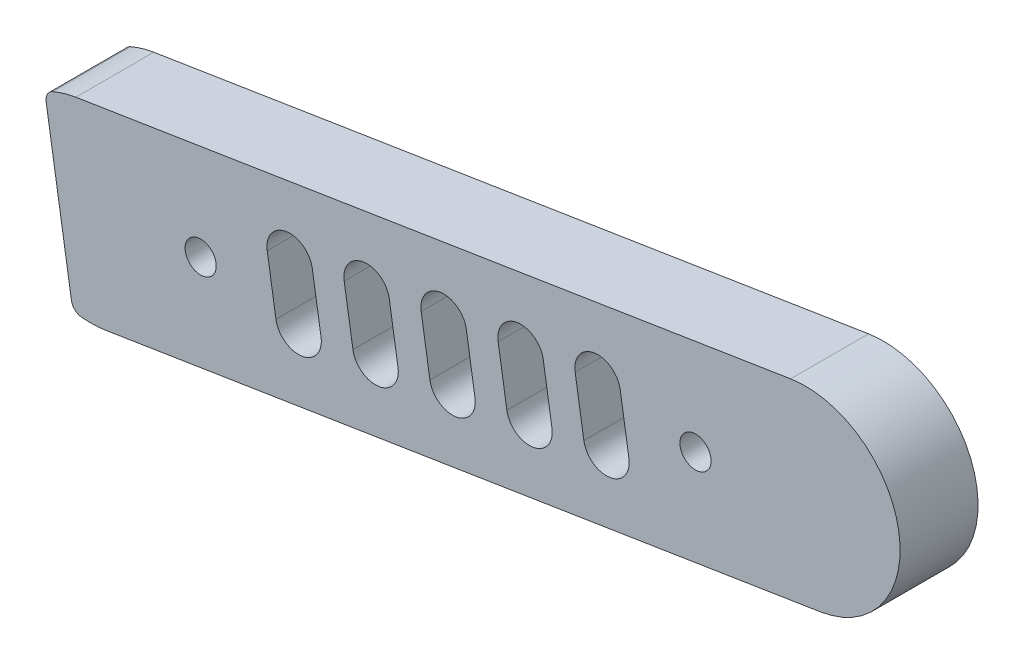
from build123d import *

# Parameters (mm, degrees)
SKETCH_1_R      = 1.4
EXTRUDE_1_DEPTH = 7


with BuildPart() as part:
    # 草图1 → 凸台-拉伸1 (new body)
    with BuildSketch(Plane.XY):
        with BuildLine():
            Line((-42.056135012, 57.617545139), (22.139601015, 67.811046791))
            ThreePointArc((22.139601015, 67.811046791), (31.867424404, 60.749216142), (24.805593755, 51.021392753))
            Line((24.805593755, 51.021392753), (-39.390142272, 40.827891101))
            ThreePointArc((-39.390142272, 40.827891101), (-40.473181997, 40.726394111), (-41.560315394, 40.764045938))
            ThreePointArc((-41.560315394, 40.764045938), (-42.147831339, 41.031589211), (-42.44945072, 41.60236074))
            Line((-42.44945072, 41.60236074), (-44.725061471, 55.933501507))
            ThreePointArc((-44.725061471, 55.933501507), (-44.615083087, 56.569629752), (-44.139340913, 57.006005475))
            ThreePointArc((-44.139340913, 57.006005475), (-43.117343546, 57.378561601), (-42.056135012, 57.617545139))
        make_face()
        with Locations((-30.846871561, 50.790949144)):
            Circle(SKETCH_1_R, mode=Mode.SUBTRACT)
        with Locations((13.596330304, 57.847988749)):
            Circle(SKETCH_1_R, mode=Mode.SUBTRACT)
        with BuildLine():
            Line((6.834080281, 59.305546509), (7.618195793, 54.367412968))
            ThreePointArc((7.618195793, 54.367412968), (5.915048401, 52.021290857), (3.568926289, 53.724438249))
            Line((3.568926289, 53.724438249), (2.784810778, 58.662571789))
            ThreePointArc((2.784810778, 58.662571789), (4.48795817, 61.008693901), (6.834080281, 59.305546509))
        make_face(mode=Mode.SUBTRACT)
        with BuildLine():
            Line((-0.079306676, 58.207784793), (0.704808836, 53.269651252))
            ThreePointArc((0.704808836, 53.269651252), (-0.998338556, 50.923529141), (-3.344460667, 52.626676532))
            Line((-3.344460667, 52.626676532), (-4.128576179, 57.564810073))
            ThreePointArc((-4.128576179, 57.564810073), (-2.425428787, 59.910932184), (-0.079306676, 58.207784793))
        make_face(mode=Mode.SUBTRACT)
        with BuildLine():
            Line((-6.992693633, 57.110023076), (-6.208578121, 52.171889536))
            ThreePointArc((-6.208578121, 52.171889536), (-7.911725513, 49.825767424), (-10.257847624, 51.528914816))
            Line((-10.257847624, 51.528914816), (-11.041963136, 56.467048357))
            ThreePointArc((-11.041963136, 56.467048357), (-9.338815744, 58.813170468), (-6.992693633, 57.110023076))
        make_face(mode=Mode.SUBTRACT)
        with BuildLine():
            Line((-13.906080589, 56.01226136), (-13.121965078, 51.074127819))
            ThreePointArc((-13.121965078, 51.074127819), (-14.82511247, 48.728005708), (-17.171234581, 50.4311531))
            Line((-17.171234581, 50.4311531), (-17.955350093, 55.36928664))
            ThreePointArc((-17.955350093, 55.36928664), (-16.252202701, 57.715408752), (-13.906080589, 56.01226136))
        make_face(mode=Mode.SUBTRACT)
        with BuildLine():
            Line((-20.819467546, 54.914499643), (-20.035352035, 49.976366103))
            ThreePointArc((-20.035352035, 49.976366103), (-21.738499426, 47.630243992), (-24.084621538, 49.333391383))
            Line((-24.084621538, 49.333391383), (-24.868737049, 54.271524924))
            ThreePointArc((-24.868737049, 54.271524924), (-23.165589658, 56.617647035), (-20.819467546, 54.914499643))
        make_face(mode=Mode.SUBTRACT)
    extrude(amount=EXTRUDE_1_DEPTH)


solid = part.part
